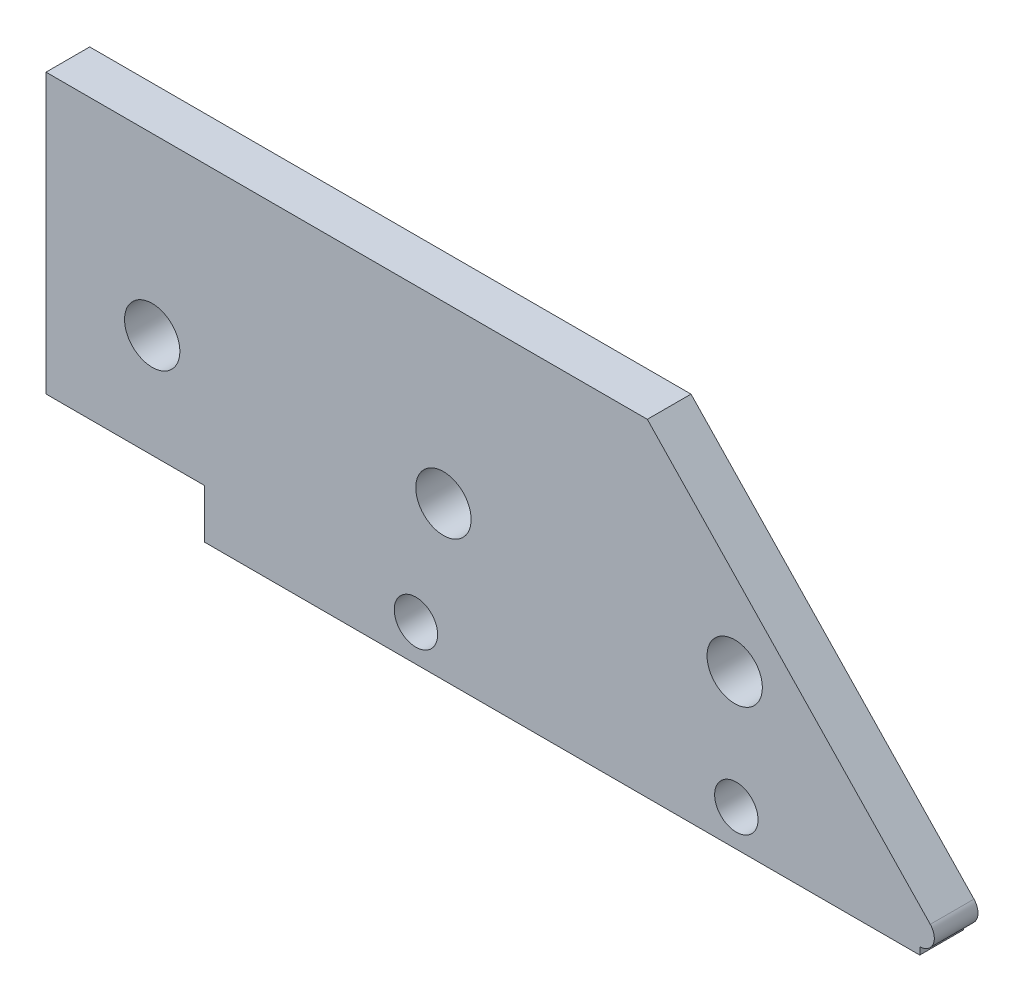
from build123d import *

# Parameters (mm, degrees)
EXTRUDE_1_DEPTH          = 3
SKETCH_2_W               = 10.886343204
SKETCH_2_H               = 8.708921112
CUT_EXTRUDE_1_DEPTH      = 1
CUT_EXTRUDE_1_DEPTH_BACK = 4
SKETCH_3_R               = 1.9
CUT_EXTRUDE_2_DEPTH      = 1
CUT_EXTRUDE_2_DEPTH_BACK = 4
SKETCH_4_R               = 1.49
CUT_EXTRUDE_3_DEPTH      = 1
CUT_EXTRUDE_3_DEPTH_BACK = 4
SKETCH_5_W               = 49.113656796
SKETCH_5_H               = 0.5
EXTRUDE_2_DEPTH          = 3


with BuildPart() as part:
    # Эскиз1 → Бобышка-Вытянуть1 (new body)
    with BuildSketch(Plane.XY):
        with BuildLine():
            Line((45.301358773, 22.383876488), (45.301358773, -1.452573816))
            Line((45.301358773, -1.452573816), (53, 0))
            Line((53, 0), (53.661481565, 0.375))
            Line((53.661481565, 0.375), (105.301358773, 0.375))
            ThreePointArc((105.301358773, 0.375), (106.2209108, 0.982031719), (106.024068331, 2.066151861))
            Line((106.024068331, 2.066151861), (86.593533576, 22.383876488))
            Line((86.593533576, 22.383876488), (45.301358773, 22.383876488))
        make_face()
    extrude(amount=EXTRUDE_1_DEPTH)

    # Эскиз2 → Вырез-Вытянуть1 (cut, two sides)
    with BuildSketch(Plane.XY.offset(3)) as cut_extrude_1_sk:
        with Locations((50.744530375, -1.111990753)):
            Rectangle(SKETCH_2_W, SKETCH_2_H)
    extrude(amount=CUT_EXTRUDE_1_DEPTH, mode=Mode.SUBTRACT)
    extrude(cut_extrude_1_sk.sketch, amount=-CUT_EXTRUDE_1_DEPTH_BACK, mode=Mode.SUBTRACT)

    # Эскиз3 → Вырез-Вытянуть2 (cut, two sides)
    with BuildSketch(Plane.XY.offset(3)) as cut_extrude_2_sk:
        with Locations((52.593533576, 10.375)):
            Circle(SKETCH_3_R)
        with Locations((72.593533576, 10.375)):
            Circle(SKETCH_3_R)
        with Locations((92.593533576, 10.375)):
            Circle(SKETCH_3_R)
    extrude(amount=CUT_EXTRUDE_2_DEPTH, mode=Mode.SUBTRACT)
    extrude(cut_extrude_2_sk.sketch, amount=-CUT_EXTRUDE_2_DEPTH_BACK, mode=Mode.SUBTRACT)

    # Эскиз4 → Вырез-Вытянуть3 (cut, two sides)
    with BuildSketch(Plane.XY.offset(3)) as cut_extrude_3_sk:
        with Locations((92.705183178, 2.375)):
            Circle(SKETCH_4_R)
        with Locations((70.705183178, 2.375)):
            Circle(SKETCH_4_R)
    extrude(amount=CUT_EXTRUDE_3_DEPTH, mode=Mode.SUBTRACT)
    extrude(cut_extrude_3_sk.sketch, amount=-CUT_EXTRUDE_3_DEPTH_BACK, mode=Mode.SUBTRACT)

    # Эскиз5 → Бобышка-Вытянуть2 (add)
    with BuildSketch(Plane.XY.offset(3)):
        with Locations((80.744530375, 0.125)):
            Rectangle(SKETCH_5_W, SKETCH_5_H)
    extrude(amount=-EXTRUDE_2_DEPTH)


solid = part.part
